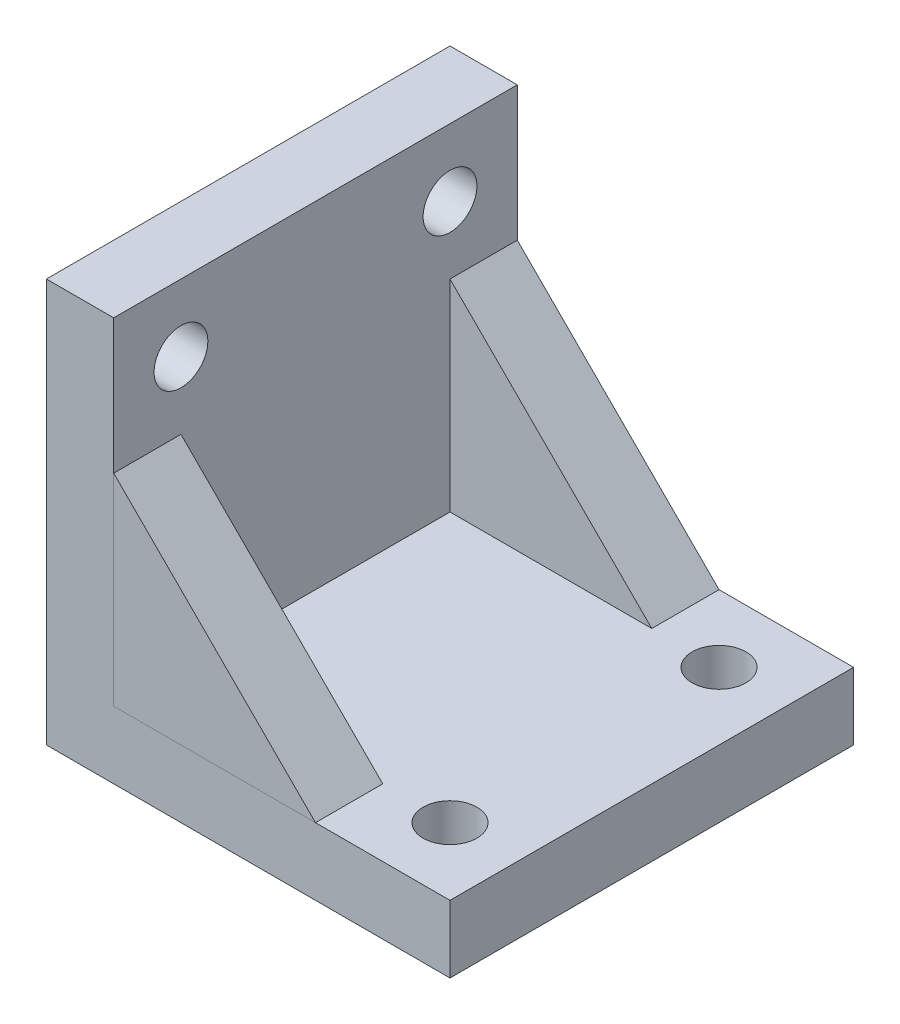
from build123d import *

# Parameters (mm, degrees)
SKETCH1_W           = 30
SKETCH1_H           = 30
BOSS_EXTRUDE1_DEPTH = 5
SKETCH2_W           = 5
SKETCH2_H           = 30
BOSS_EXTRUDE2_DEPTH = 25
BOSS_EXTRUDE3_DEPTH = 5
BOSS_EXTRUDE4_DEPTH = 5
SKETCH10_R          = 2
CUT_EXTRUDE1_DEPTH  = 5
SKETCH11_R          = 2
CUT_EXTRUDE2_DEPTH  = 5


with BuildPart() as part:
    # Sketch1 → Boss-Extrude1 (new body)
    with BuildSketch(Plane(origin=(0, 0, 0), x_dir=(1, 0, 0), z_dir=(0, 1, 0))):
        Rectangle(SKETCH1_W, SKETCH1_H)
    extrude(amount=BOSS_EXTRUDE1_DEPTH)

    # Sketch2 → Boss-Extrude2 (add)
    with BuildSketch(Plane(origin=(0, 5, 0), x_dir=(1, 0, 0), z_dir=(0, 1, 0))):
        with Locations((-12.5, 0)):
            Rectangle(SKETCH2_W, SKETCH2_H)
    extrude(amount=BOSS_EXTRUDE2_DEPTH)

    # Sketch5 → Boss-Extrude4 (add)
    with BuildSketch(Plane.XY.offset(-15)):
        Polygon((-10, 5), (-10, 20), (5, 5), align=None)
    extrude(amount=BOSS_EXTRUDE4_DEPTH)

    # Sketch10 → Cut-Extrude1 (cut)
    with BuildSketch(Plane(origin=(-10, 0, 0), x_dir=(0, 0, -1), z_dir=(1, 0, 0))):
        with Locations((-10, 25)):
            Circle(SKETCH10_R)
        with Locations((10, 25)):
            Circle(SKETCH10_R)
    extrude(amount=-CUT_EXTRUDE1_DEPTH, mode=Mode.SUBTRACT)

    # Sketch11 → Cut-Extrude2 (cut)
    with BuildSketch(Plane(origin=(0, 5, 0), x_dir=(1, 0, 0), z_dir=(0, 1, 0))):
        with Locations((10, 10)):
            Circle(SKETCH11_R)
        with Locations((10, -10)):
            Circle(SKETCH11_R)
    extrude(amount=-CUT_EXTRUDE2_DEPTH, mode=Mode.SUBTRACT)


with BuildPart() as body_2:
    # Sketch3 → Boss-Extrude3 (new body)
    with BuildSketch(Plane.XY.offset(15)):
        Polygon((-10, 5), (-10, 20), (5, 5), align=None)
    extrude(amount=-BOSS_EXTRUDE3_DEPTH)


solid = Compound([part.part, body_2.part])
